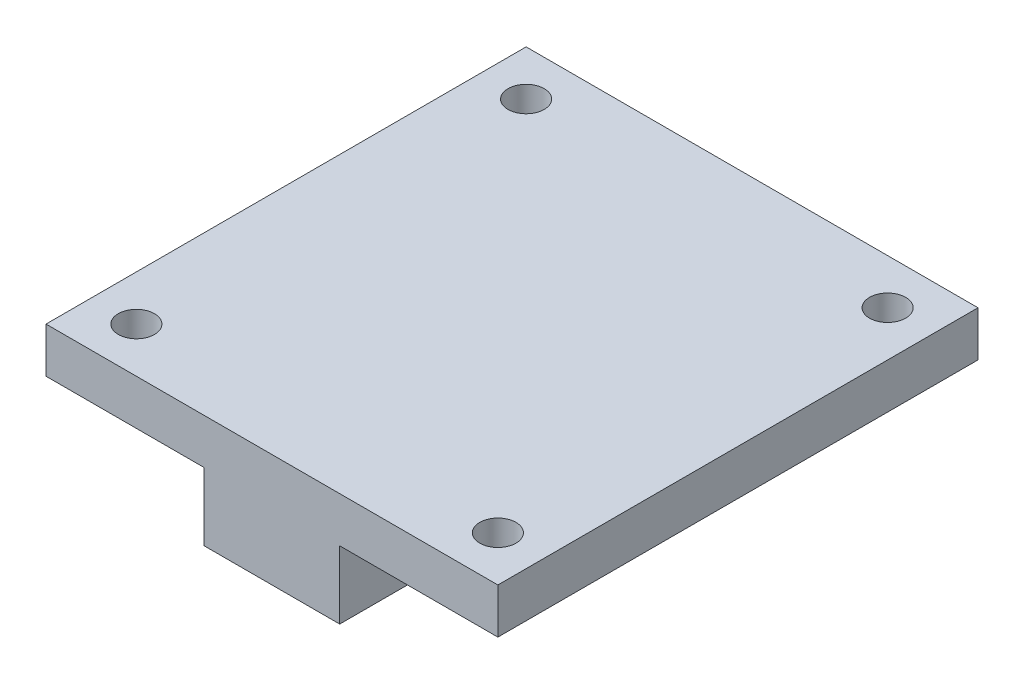
from build123d import *

# Parameters (mm, degrees)
BOSS_EXTRU_1_DEPTH      = 42.5
D_GAGEMENT_M31_D        = 3
D_GAGEMENT_M33_D        = 3.2
ENL_V_MAT_EXTRU_1_DEPTH = 1


with BuildPart() as part:
    # Esquisse1 → Boss.-Extru.1 (new body)
    with BuildSketch(Plane(origin=(0, 0, 0), x_dir=(1, 0, 0), z_dir=(0, 0, -1))):
        Polygon((-1.384510159, -46.220398701), (38.615489841, -46.220398701), (38.615489841, -42.220398701), (24.615489841, -42.220398701), (24.615489841, -36.220398701), (12.615489841, -36.220398701), (12.615489841, -42.220398701), (-1.384510159, -42.220398701), align=None)
    extrude(amount=BOSS_EXTRU_1_DEPTH)

    # Dégagement M31 (through all)
    with Locations(Plane(origin=(24.615489841, 0, 0), x_dir=(0, 0, -1), z_dir=(1, 0, 0))):
        with Locations((10, 39.220398701), (32.5, 39.220398701)):
            Hole(D_GAGEMENT_M31_D / 2)

    # Dégagement M33 (through all)
    with Locations(Plane(origin=(0, 42.220398701, 0), x_dir=(-1, 0, 0), z_dir=(0, -1, 0))):
        with Locations((3, -59.94627318), (-34.615489841, 38.5), (-2.615489841, 38.5), (-2.615489841, 4), (-34.615489841, 4)):
            Hole(D_GAGEMENT_M33_D / 2)

    # Esquisse9 → Enlèv. mat.-Extru.1 (cut)
    with BuildSketch(Plane.XZ.offset(-42.220398701)):
        Polygon((32.865489841, -35.468911087), (31.115489841, -38.5), (32.865489841, -41.531088913), (36.365489841, -41.531088913), (38.115489841, -38.5), (36.365489841, -35.468911087), align=None)
        Polygon((4.365489841, -35.468911087), (0.865489841, -35.468911087), (-0.884510159, -38.5), (0.865489841, -41.531088913), (4.365489841, -41.531088913), (6.115489841, -38.5), align=None)
        Polygon((32.865489841, -0.968911087), (31.115489841, -4), (32.865489841, -7.031088913), (36.365489841, -7.031088913), (38.115489841, -4), (36.365489841, -0.968911087), align=None)
        Polygon((4.365489841, -0.968911087), (0.865489841, -0.968911087), (-0.884510159, -4), (0.865489841, -7.031088913), (4.365489841, -7.031088913), (6.115489841, -4), align=None)
    extrude(amount=-ENL_V_MAT_EXTRU_1_DEPTH, mode=Mode.SUBTRACT)


solid = part.part
